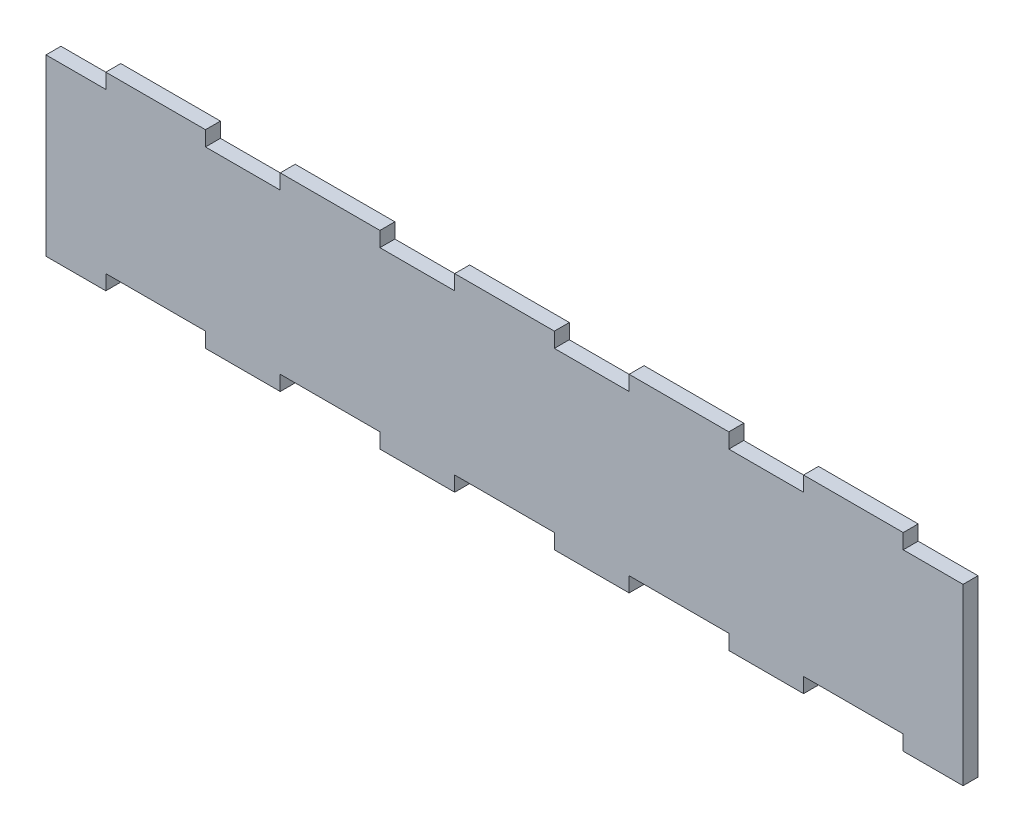
from build123d import *

# Parameters (mm, degrees)
BOSS_EXTRUDE1_DEPTH = 3


with BuildPart() as part:
    # Sketch1 → Boss-Extrude1 (new body)
    with BuildSketch(Plane(origin=(0, 0, 0), x_dir=(1, 0, 0), z_dir=(0, 0, -1))):
        Polygon((32, 0), (47, 0), (47, -3), (67, -3), (67, 0), (82, 0), (82, -3), (102, -3), (102, 0), (117, 0), (117, -3), (137, -3), (137, 0), (152, 0), (152, -3), (172, -3), (172, 0), (184, 0), (184, 35), (172, 35), (172, 32), (152, 32), (152, 35), (137, 35), (137, 32), (117, 32), (117, 35), (102, 35), (102, 32), (82, 32), (82, 35), (67, 35), (67, 32), (47, 32), (47, 35), (32, 35), (32, 32), (12, 32), (12, 35), (0, 35), (0, 0), (12, 0), (12, -3), (32, -3), align=None)
    extrude(amount=BOSS_EXTRUDE1_DEPTH)


solid = part.part
